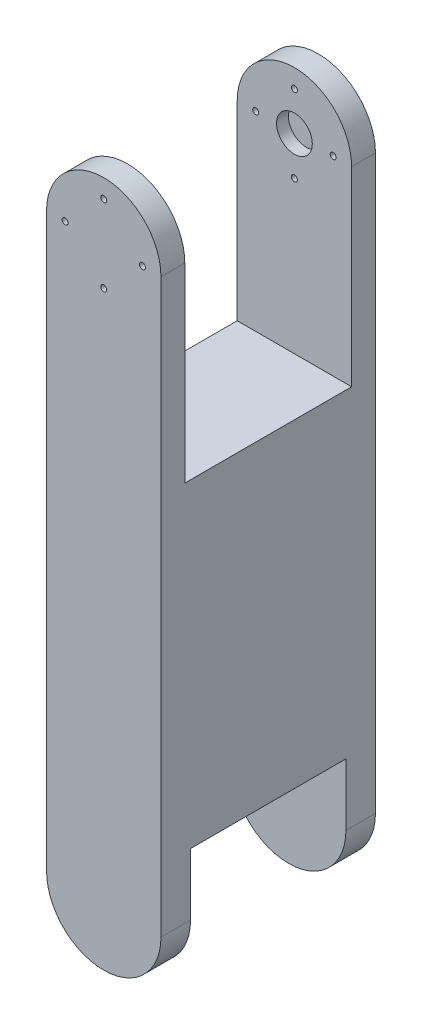
from build123d import *

# Parameters (mm, degrees)
BOSS_EXTRUDE1_DEPTH = 57.15
SKETCH2_W           = 44.45
SKETCH2_H           = 66.04
CUT_EXTRUDE1_DEPTH  = 57.15
SKETCH6_R           = 4.7625
CUT_EXTRUDE3_DEPTH  = 3.175
SKETCH8_R           = 0.79375
CUT_EXTRUDE4_DEPTH  = 58.15
SKETCH9_W           = 41.402
SKETCH9_H           = 31.75
CUT_EXTRUDE5_DEPTH  = 31.48


with BuildPart() as part:
    # Sketch1 → Boss-Extrude1 (new body)
    with BuildSketch(Plane.XY):
        with BuildLine():
            Line((-15.24, 76.2), (-15.24, -76.2))
            ThreePointArc((-15.24, -76.2), (0, -91.44), (15.24, -76.2))
            Line((15.24, -76.2), (15.24, 76.2))
            ThreePointArc((15.24, 76.2), (0, 91.44), (-15.24, 76.2))
        make_face()
    extrude(amount=BOSS_EXTRUDE1_DEPTH)

    # Sketch2 → Cut-Extrude1 (cut)
    with BuildSketch(Plane(origin=(15.24, 0, 0), x_dir=(0, 0, -1), z_dir=(1, 0, 0))):
        with Locations((-28.575, 58.42)):
            Rectangle(SKETCH2_W, SKETCH2_H)
    extrude(amount=-CUT_EXTRUDE1_DEPTH, mode=Mode.SUBTRACT)

    # Sketch6 → Cut-Extrude3 (cut)
    with BuildSketch(Plane.XY.offset(6.35)):
        with Locations((0, 76.2)):
            Circle(SKETCH6_R)
    extrude(amount=-CUT_EXTRUDE3_DEPTH, mode=Mode.SUBTRACT)

    # Sketch8 → Cut-Extrude4 (cut, through all)
    with BuildSketch(Plane(origin=(0, 0, 0), x_dir=(-1, 0, 0), z_dir=(0, 0, -1))):
        with Locations((0, 65.88125)):
            Circle(SKETCH8_R)
        with Locations((-10.31875, 76.2)):
            Circle(SKETCH8_R)
        with Locations((0, 86.51875)):
            Circle(SKETCH8_R)
        with Locations((10.31875, 76.2)):
            Circle(SKETCH8_R)
    extrude(amount=-CUT_EXTRUDE4_DEPTH, mode=Mode.SUBTRACT)

    # Sketch9 → Cut-Extrude5 (cut, through all)
    with BuildSketch(Plane(origin=(15.24, 0, 0), x_dir=(0, 0, -1), z_dir=(1, 0, 0))):
        with Locations((-28.575, -75.565)):
            Rectangle(SKETCH9_W, SKETCH9_H)
    extrude(amount=-CUT_EXTRUDE5_DEPTH, mode=Mode.SUBTRACT)


solid = part.part
